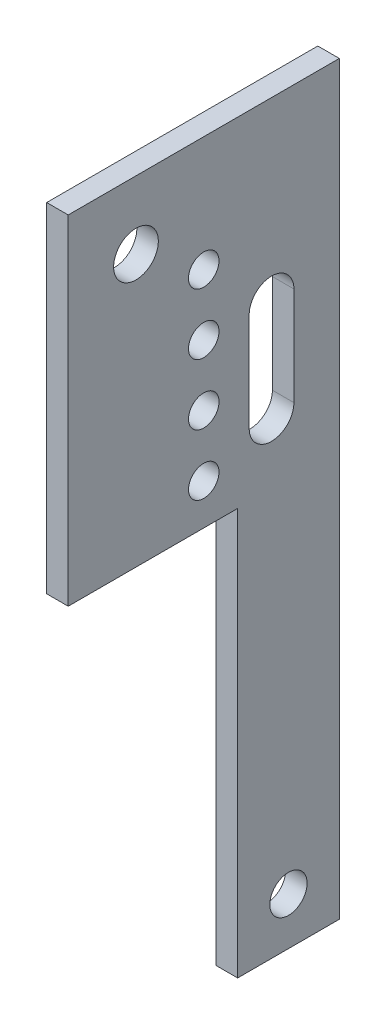
from build123d import *

# Parameters (mm, degrees)
SKETCH1_R           = 3.3
SKETCH1_R_2         = 2.25
SKETCH1_R_3         = 2.75
BOSS_EXTRUDE1_DEPTH = 3.175


with BuildPart() as part:
    # Sketch1 → Boss-Extrude1 (new body)
    with BuildSketch(Plane(origin=(0, 0, 0), x_dir=(0, 0, -1), z_dir=(1, 0, 0))):
        Polygon((40, 0), (0, 0), (0, -50), (25, -50), (25, -110), (40, -110), (40, -50), align=None)
        with Locations((10, -10)):
            Circle(SKETCH1_R, mode=Mode.SUBTRACT)
        with Locations((20, -16.974849628)):
            Circle(SKETCH1_R_2, mode=Mode.SUBTRACT)
        with Locations((20, -25.974849628)):
            Circle(SKETCH1_R_2, mode=Mode.SUBTRACT)
        with Locations((20, -34.974849628)):
            Circle(SKETCH1_R_2, mode=Mode.SUBTRACT)
        with Locations((20, -43.974849628)):
            Circle(SKETCH1_R_2, mode=Mode.SUBTRACT)
        with Locations((32.5, -103)):
            Circle(SKETCH1_R_3, mode=Mode.SUBTRACT)
        with BuildLine():
            Line((33.3, -26.108433688), (33.3, -40.629208547))
            ThreePointArc((33.3, -40.629208547), (30, -43.929208547), (26.7, -40.629208547))
            Line((26.7, -40.629208547), (26.7, -26.108433688))
            ThreePointArc((26.7, -26.108433688), (30, -22.808433688), (33.3, -26.108433688))
        make_face(mode=Mode.SUBTRACT)
    extrude(amount=BOSS_EXTRUDE1_DEPTH)


solid = part.part
